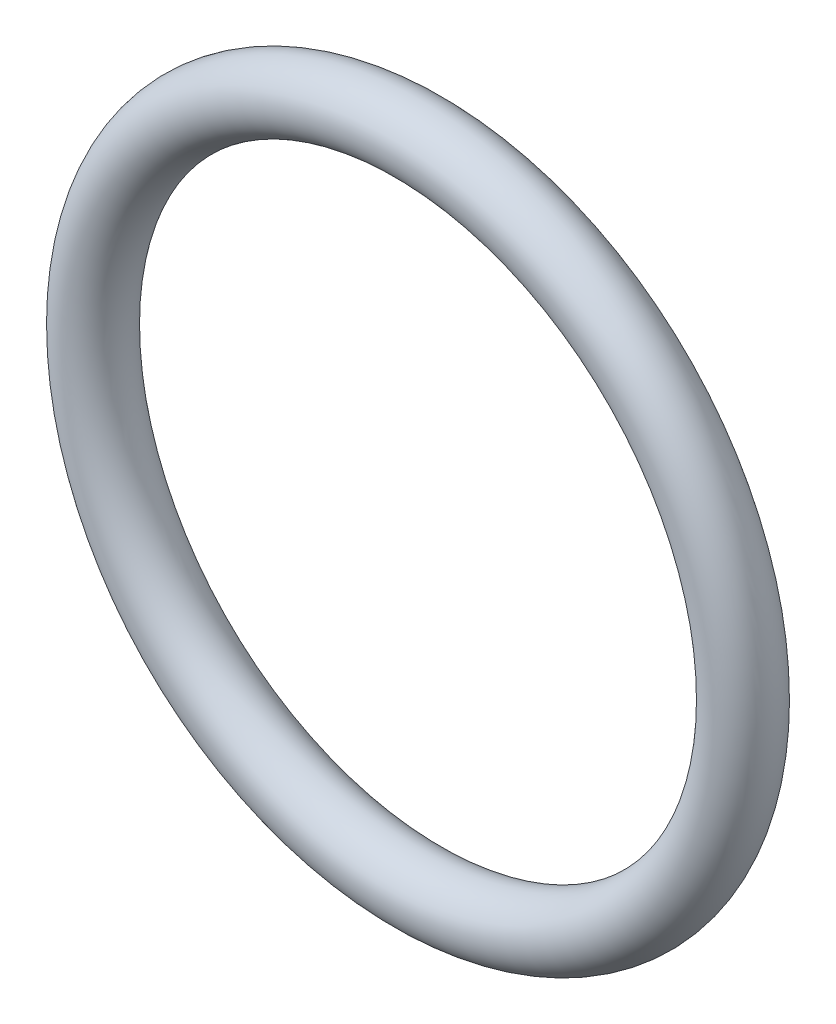
from build123d import *

# Parameters (mm, degrees)
SKETCH2_R = 1.7653


with BuildPart() as part:
    # Sketch2 → Revolve1 (revolve)
    with BuildSketch(Plane(origin=(0, 0, 0), x_dir=(1, 0, 0), z_dir=(0, 1, 0))):
        with Locations((-17.4371, 0)):
            Circle(SKETCH2_R)
    revolve(axis=Axis((0, 0, 1.7653), (0, 0, -1)))


solid = part.part
